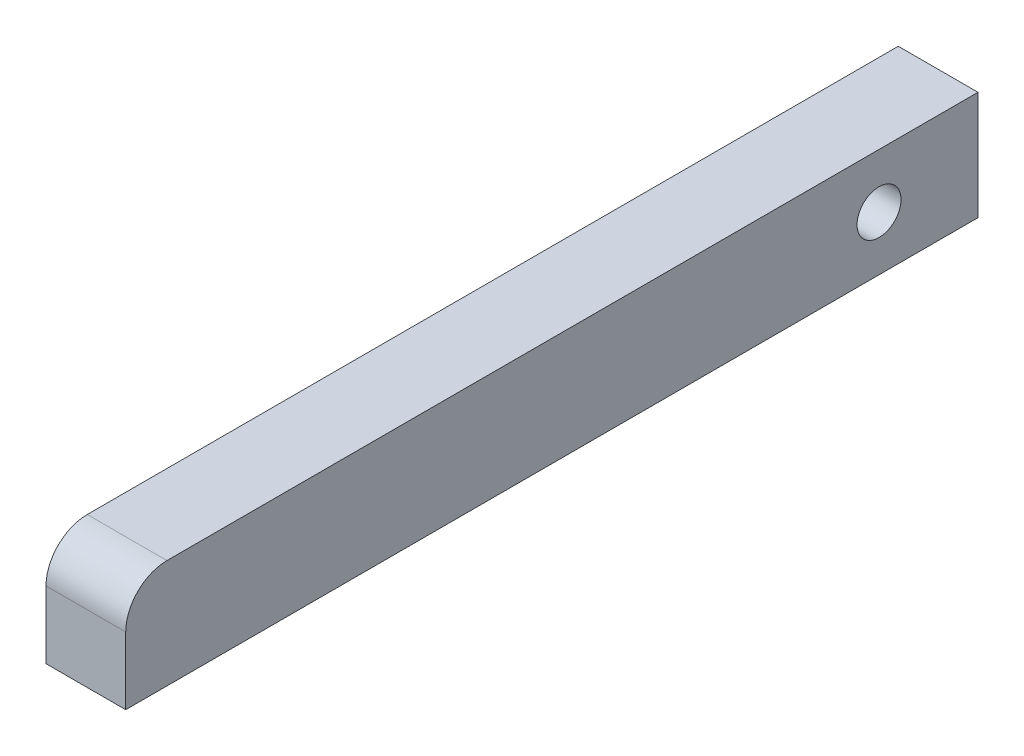
from build123d import *

# Parameters (mm, degrees)
SKETCH1_W           = 5.8
SKETCH1_H           = 7.9
BOSS_EXTRUDE1_DEPTH = 62
SKETCH2_R           = 1.6
CUT_EXTRUDE1_DEPTH  = 6.8
FILLET1_R           = 3


with BuildPart() as part:
    # Sketch1 → Boss-Extrude1 (new body)
    with BuildSketch(Plane.XY):
        Rectangle(SKETCH1_W, SKETCH1_H)
    extrude(amount=BOSS_EXTRUDE1_DEPTH)

    # Sketch2 → Cut-Extrude1 (cut, through all)
    with BuildSketch(Plane(origin=(2.9, 0, 0), x_dir=(0, 0, -1), z_dir=(1, 0, 0))):
        with Locations((-7.2, 0)):
            Circle(SKETCH2_R)
    extrude(amount=-CUT_EXTRUDE1_DEPTH, mode=Mode.SUBTRACT)

    # Fillet1
    fillet1_edges = [part.edges().sort_by_distance(p)[0] for p in [
        (0, 3.95, 62),
    ]]
    fillet(fillet1_edges, radius=FILLET1_R)


solid = part.part
